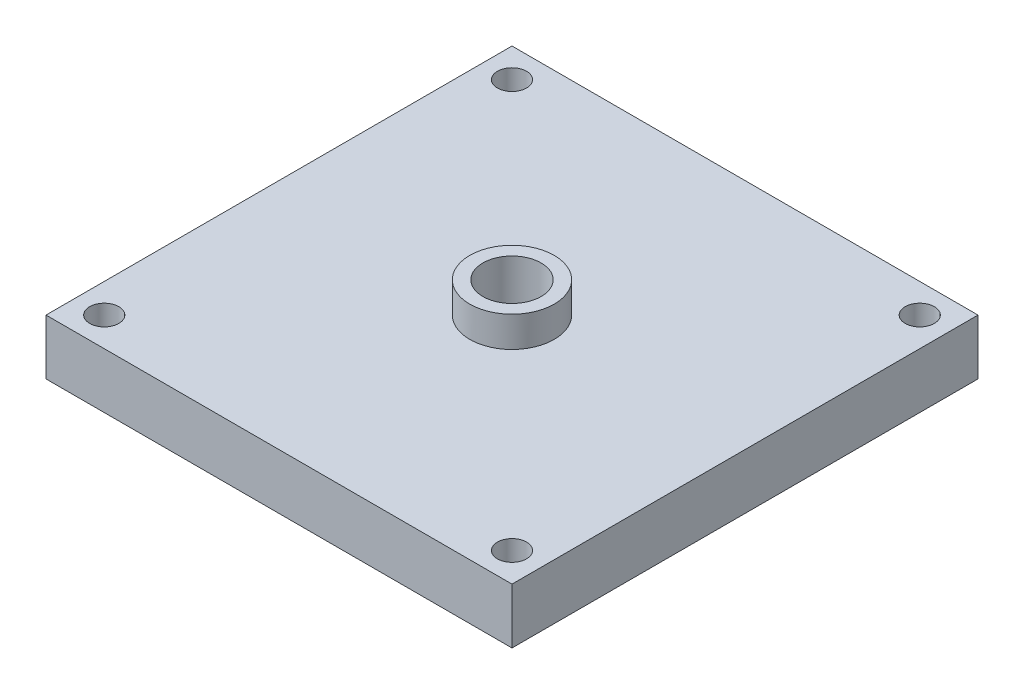
from build123d import *

# Parameters (mm, degrees)
SKETCH1_W           = 80
SKETCH1_H           = 80
SKETCH1_R           = 2.5
BOSS_EXTRUDE1_DEPTH = 9.5
SKETCH3_R           = 5
CUT_EXTRUDE1_DEPTH  = 4.75
SKETCH10_R          = 7.25
SKETCH10_R_2        = 5
BOSS_EXTRUDE3_DEPTH = 10


with BuildPart() as part:
    # Sketch1 → Boss-Extrude1 (new body)
    with BuildSketch(Plane(origin=(0, 0, 0), x_dir=(1, 0, 0), z_dir=(0, 1, 0))):
        with Locations((40, 40)):
            Rectangle(SKETCH1_W, SKETCH1_H)
        with Locations((5, 75)):
            Circle(SKETCH1_R, mode=Mode.SUBTRACT)
        with Locations((75, 75)):
            Circle(SKETCH1_R, mode=Mode.SUBTRACT)
        with Locations((75, 5)):
            Circle(SKETCH1_R, mode=Mode.SUBTRACT)
        with Locations((5, 5)):
            Circle(SKETCH1_R, mode=Mode.SUBTRACT)
    extrude(amount=BOSS_EXTRUDE1_DEPTH)

    # Sketch3 → Cut-Extrude1 (cut, symmetric)
    with BuildSketch(Plane(origin=(0, 9.5, 0), x_dir=(1, 0, 0), z_dir=(0, 1, 0))):
        with Locations((40, 40)):
            Circle(SKETCH3_R)
    extrude(amount=CUT_EXTRUDE1_DEPTH, both=True, mode=Mode.SUBTRACT)

    # Sketch10 → Boss-Extrude3 (add)
    with BuildSketch(Plane(origin=(0, 4.75, 0), x_dir=(1, 0, 0), z_dir=(0, 1, 0))):
        with Locations((40, 40)):
            Circle(SKETCH10_R)
        with Locations((40, 40)):
            Circle(SKETCH10_R_2, mode=Mode.SUBTRACT)
    extrude(amount=BOSS_EXTRUDE3_DEPTH)


solid = part.part
